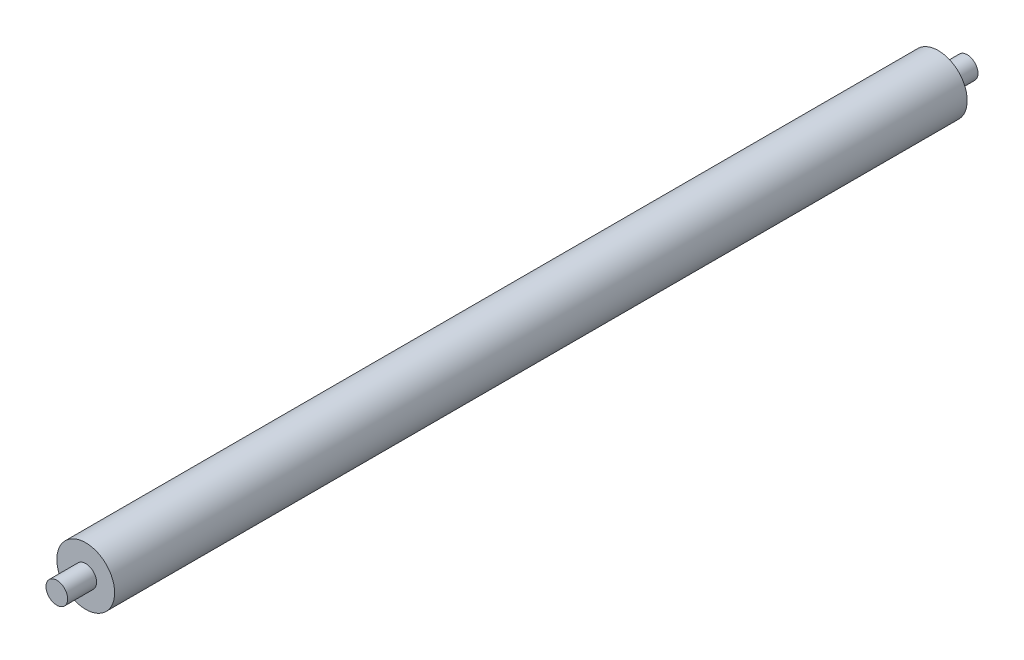
from build123d import *

# Parameters (mm, degrees)
SKETCH_1_R      = 4
EXTRUDE_1_DEPTH = 118
SKETCH_2_R      = 1.5
EXTRUDE_2_DEPTH = 4
SKETCH_3_R      = 1.5
EXTRUDE_3_DEPTH = 4


with BuildPart() as part:
    # 草图1 → 凸台-拉伸1 (new body)
    with BuildSketch(Plane.XY):
        Circle(SKETCH_1_R)
    extrude(amount=EXTRUDE_1_DEPTH)

    # 草图2 → 凸台-拉伸2 (add)
    with BuildSketch(Plane(origin=(0, 0, 0), x_dir=(-1, 0, 0), z_dir=(0, 0, -1))):
        Circle(SKETCH_2_R)
    extrude(amount=EXTRUDE_2_DEPTH)

    # 草图3 → 凸台-拉伸3 (add)
    with BuildSketch(Plane.XY.offset(118)):
        Circle(SKETCH_3_R)
    extrude(amount=EXTRUDE_3_DEPTH)


solid = part.part
